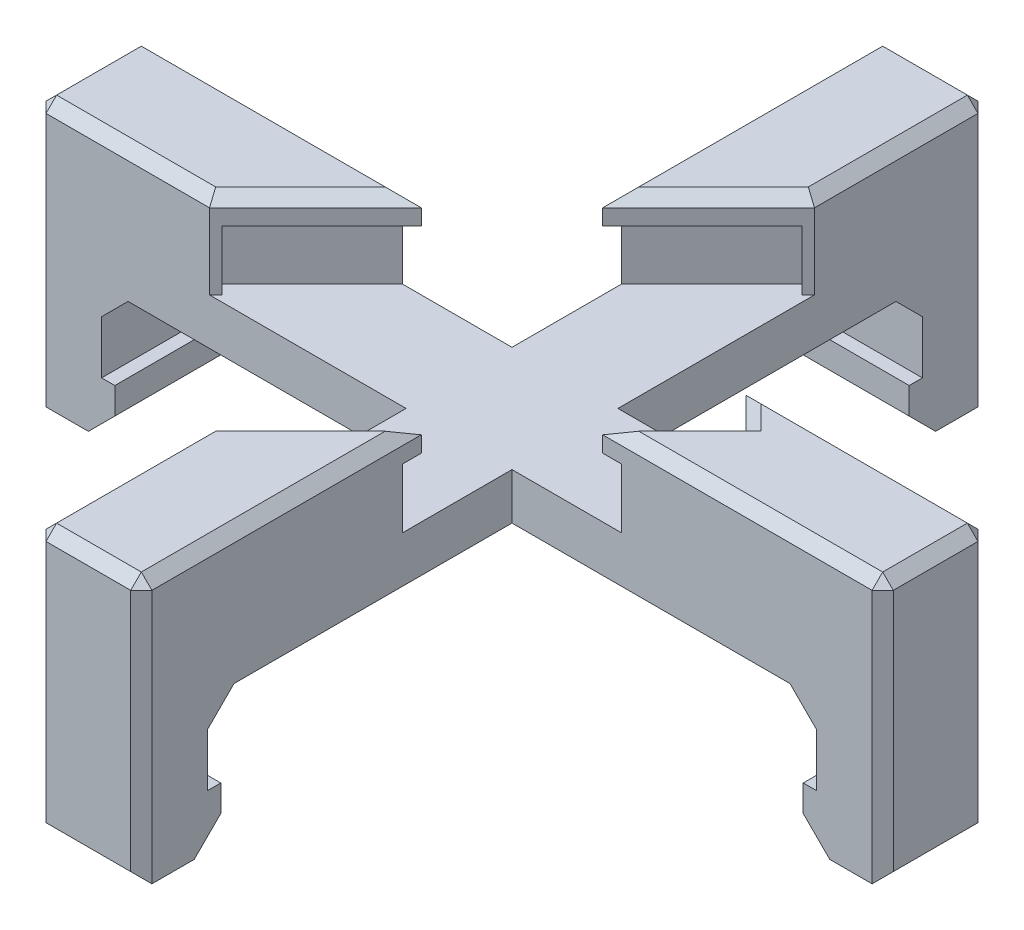
from build123d import *

# Parameters (mm, degrees)
SKETCH1_W               = 31.999999976
SKETCH1_H               = 4
BOSS_EXTRUDE1_DEPTH     = 5
SKETCH2_W               = 2.499999921
SKETCH2_H               = 4
BOSS_EXTRUDE2_DEPTH     = 3
SKETCH3_W               = 2.999999921
SKETCH3_H               = 4
BOSS_EXTRUDE3_DEPTH     = 2
CIRPATTERN1_COUNT       = 2
CIRPATTERN1_ANGLE       = 90
CUT_EXTRUDE1_DEPTH      = 3.250000112
BOSS_EXTRUDE4_DEPTH     = 1
CUT_EXTRUDE_THIN1_START = -3.25
CUT_EXTRUDE_THIN1_DEPTH = 3.25
CUT_EXTRUDE_THIN2_START = -3.25
CUT_EXTRUDE_THIN2_DEPTH = 3.25
CHAMFER2_SIZE           = 1
CHAMFER3_SIZE           = 0.4


with BuildPart() as part:
    # Sketch1 → Boss-Extrude1 (new body)
    with BuildSketch(Plane(origin=(0, 0, 0), x_dir=(1, 0, 0), z_dir=(0, 1, 0))):
        Rectangle(SKETCH1_W, SKETCH1_H)
    extrude(amount=BOSS_EXTRUDE1_DEPTH)

    # Sketch2 → Boss-Extrude2 (add)
    with BuildSketch(Plane.XZ):
        with Locations((14.750000028, 0)):
            Rectangle(SKETCH2_W, SKETCH2_H)
        with Locations((-14.750000028, 0)):
            Rectangle(SKETCH2_W, SKETCH2_H)
    extrude(amount=BOSS_EXTRUDE2_DEPTH)

    # Sketch3 → Boss-Extrude3 (add)
    with BuildSketch(Plane.XZ.offset(3)):
        with Locations((14.500000028, 0)):
            Rectangle(SKETCH3_W, SKETCH3_H)
        with Locations((-14.500000028, 0)):
            Rectangle(SKETCH3_W, SKETCH3_H)
    extrude(amount=BOSS_EXTRUDE3_DEPTH)

    # CirPattern1: part ×2 about axis
    cirpattern1_axis = Axis((0, 0, 0), (0, 1, 0))


with BuildPart() as part_1:
    add(part.part)
    for i in range(1, CIRPATTERN1_COUNT):
        add(part.part.rotate(cirpattern1_axis, i * CIRPATTERN1_ANGLE / (CIRPATTERN1_COUNT - 1)))

    # Sketch6 → Cut-Extrude1 (cut)
    with BuildSketch(Plane(origin=(0, 5, 0), x_dir=(1, 0, 0), z_dir=(0, 1, 0))):
        Polygon((-1.414213562, -9.545941546), (-9.545941546, -1.414213562), (1.414213562, 9.545941546), (6.01040764, 4.949747468), (4.949747468, 3.889087297), (8.485281374, 0.353553391), align=None)
    extrude(amount=-CUT_EXTRUDE1_DEPTH, mode=Mode.SUBTRACT)

    # Sketch7 → Boss-Extrude4 (add)
    with BuildSketch(Plane(origin=(0, 5, 0), x_dir=(1, 0, 0), z_dir=(0, 1, 0))):
        Polygon((-9.545941546, -1.414213562), (-9.192388155, -1.767766953), (-5.424621202, 2), (-6.131727984, 2), align=None)
        Polygon((1.767766953, 9.192388155), (1.414213562, 9.545941546), (-2, 6.131727984), (-2, 5.424621202), align=None)
        Polygon((8.131727984, 0.707106781), (8.485281374, 0.353553391), (6.131727984, -2), (5.424621202, -2), align=None)
        Polygon((2, -5.424621202), (2, -6.131727984), (-1.414213562, -9.545941546), (-1.767766953, -9.192388155), align=None)
    extrude(amount=-BOSS_EXTRUDE4_DEPTH)

    # Sketch8 → Cut-Extrude-Thin1 (cut)
    with BuildSketch(Plane(origin=(0, 5, 0), x_dir=(1, 0, 0), z_dir=(0, 1, 0)).offset(CUT_EXTRUDE_THIN1_START)):
        Polygon((-9.424621202, -2), (2, 9.424621202), (3.796051224, 7.628569978), (-7.628569978, -3.796051224), align=None)
    extrude(amount=CUT_EXTRUDE_THIN1_DEPTH, mode=Mode.SUBTRACT)

    # Sketch9 → Cut-Extrude-Thin2 (cut)
    with BuildSketch(Plane(origin=(0, 5, 0), x_dir=(1, 0, 0), z_dir=(0, 1, 0)).offset(CUT_EXTRUDE_THIN2_START)):
        Polygon((2, -5.424621202), (-2, -9.424621202), (-3.796051224, -7.628569978), (0.203948776, -3.628569978), align=None)
    extrude(amount=CUT_EXTRUDE_THIN2_DEPTH, mode=Mode.SUBTRACT)

    # Chamfer2
    chamfer2_edges = [part_1.edges().sort_by_distance(p)[0] for p in [
        (0, 0, 13.500000067),
        (0, -5, -13.000000067),
        (0, -5, 13.000000067),
        (13.500000067, 0, 0),
        (-13.500000067, 0, 0),
        (13.000000067, -5, 0),
        (-13.000000067, -5, 0),
        (0, 0, -13.500000067),
    ]]
    chamfer(chamfer2_edges, length=CHAMFER2_SIZE)

    # Chamfer3
    chamfer3_edges = [part_1.edges().sort_by_distance(p)[0] for p in [
        (15.999999988, 5, 0),
        (0, -5, -15.999999988),
        (0, -5, 15.999999988),
        (11.419417376, 5, -2),
        (10.712310595, 5, 2),
        (-10.712310595, 5, -2),
        (-7.424621202, 5, 0),
        (0, 5, -7.424621202),
        (7.485281374, 5, -1.353553391),
        (6.778174593, 5, 0.646446609),
        (0, 5, 7.424621202),
        (2, 5, -12.712310595),
        (-2, 5, 12.712310595),
        (15.999999988, -5, 0),
        (-15.999999988, 5, 0),
        (-15.999999988, -5, 0),
        (-12.712310595, 5, 2),
        (0, 5, 15.999999988),
        (2, 5, 10.712310595),
        (0, 5, -15.999999988),
        (-2, 5, -10.712310595),
        (2, 0, 15.999999988),
        (-2, 0, -15.999999988),
        (-15.999999988, 0, -2),
        (-2, 0, 15.999999988),
        (2, 0, -15.999999988),
        (15.999999988, 0, -2),
        (15.999999988, 0, 2),
        (-15.999999988, 0, 2),
    ]]
    chamfer(chamfer3_edges, length=CHAMFER3_SIZE)


solid = part_1.part
